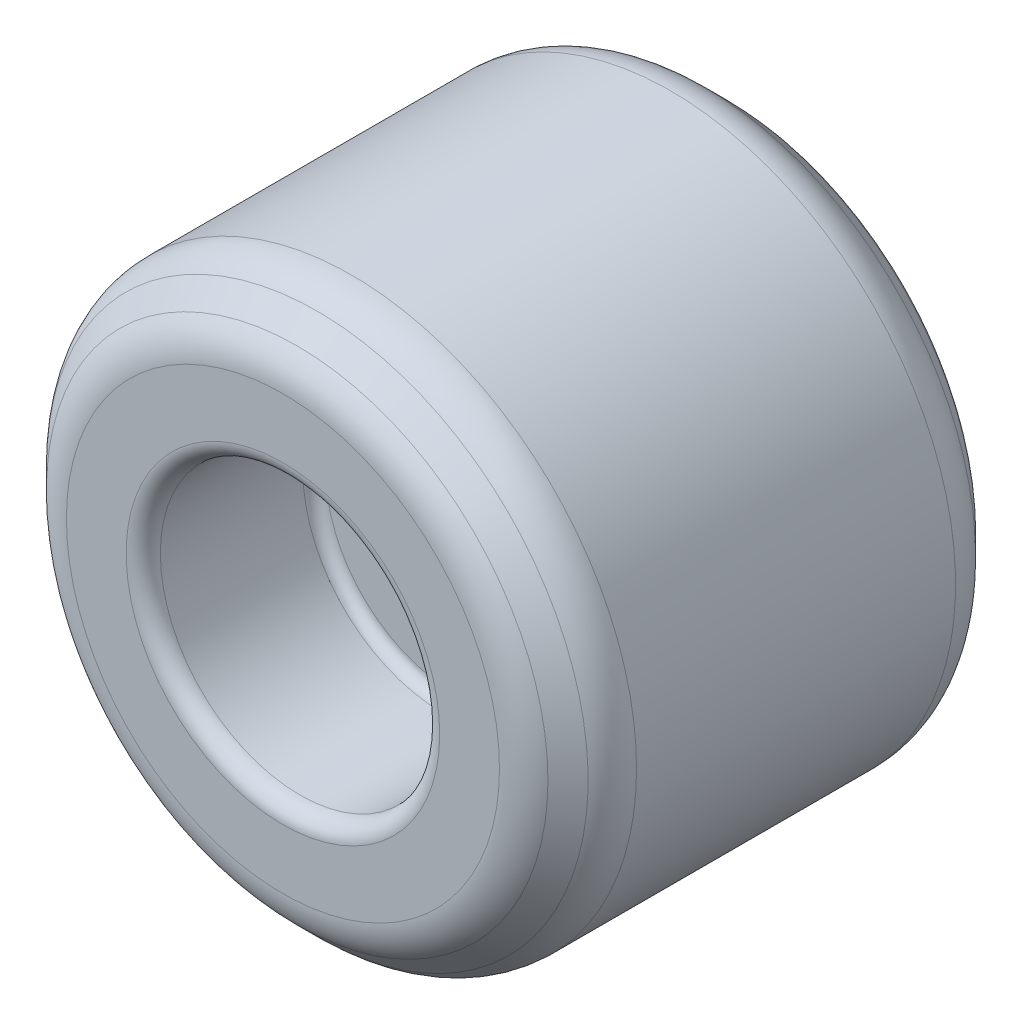
from build123d import *

# Parameters (mm, degrees)
SKETCH1_R           = 6.35
BOSS_EXTRUDE1_DEPTH = 10.16
SKETCH2_R           = 3.1115
CUT_EXTRUDE1_DEPTH  = 3.81
CHAMFER1_SIZE       = 1.0795
FILLET1_R           = 0.254
FILLET2_R           = 0.381
FILLET3_R           = 1.0795


with BuildPart() as part:
    # Sketch1 → Boss-Extrude1 (new body)
    with BuildSketch(Plane.XY):
        Circle(SKETCH1_R)
    extrude(amount=BOSS_EXTRUDE1_DEPTH)

    # Sketch2 → Cut-Extrude1 (cut)
    with BuildSketch(Plane.XY.offset(10.16)):
        Circle(SKETCH2_R)
    cut_extrude1 = extrude(amount=-CUT_EXTRUDE1_DEPTH, mode=Mode.SUBTRACT)

    # Mirror1: Cut-Extrude1 across plane
    add(cut_extrude1.mirror(Plane.XY.offset(5.08)), mode=Mode.SUBTRACT)

    # Chamfer1
    chamfer1_edges = [part.edges().sort_by_distance(p)[0] for p in [
        (-6.35, 0, 0),
        (-6.35, 0, 10.16),
    ]]
    chamfer(chamfer1_edges, length=CHAMFER1_SIZE)

    # Fillet1
    fillet1_edges = [part.edges().sort_by_distance(p)[0] for p in [
        (-3.1115, 0, 3.81),
        (-3.1115, 0, 6.35),
    ]]
    fillet(fillet1_edges, radius=FILLET1_R)

    # Fillet2
    fillet2_edges = [part.edges().sort_by_distance(p)[0] for p in [
        (-3.1115, 0, 0),
        (-3.1115, 0, 10.16),
    ]]
    fillet(fillet2_edges, radius=FILLET2_R)

    # Fillet3
    fillet3_edges = [part.edges().sort_by_distance(p)[0] for p in [
        (-6.35, 0, 9.0805),
        (-6.35, 0, 1.0795),
        (-5.2705, 0, 0),
        (-5.2705, 0, 10.16),
    ]]
    fillet(fillet3_edges, radius=FILLET3_R)


solid = part.part
